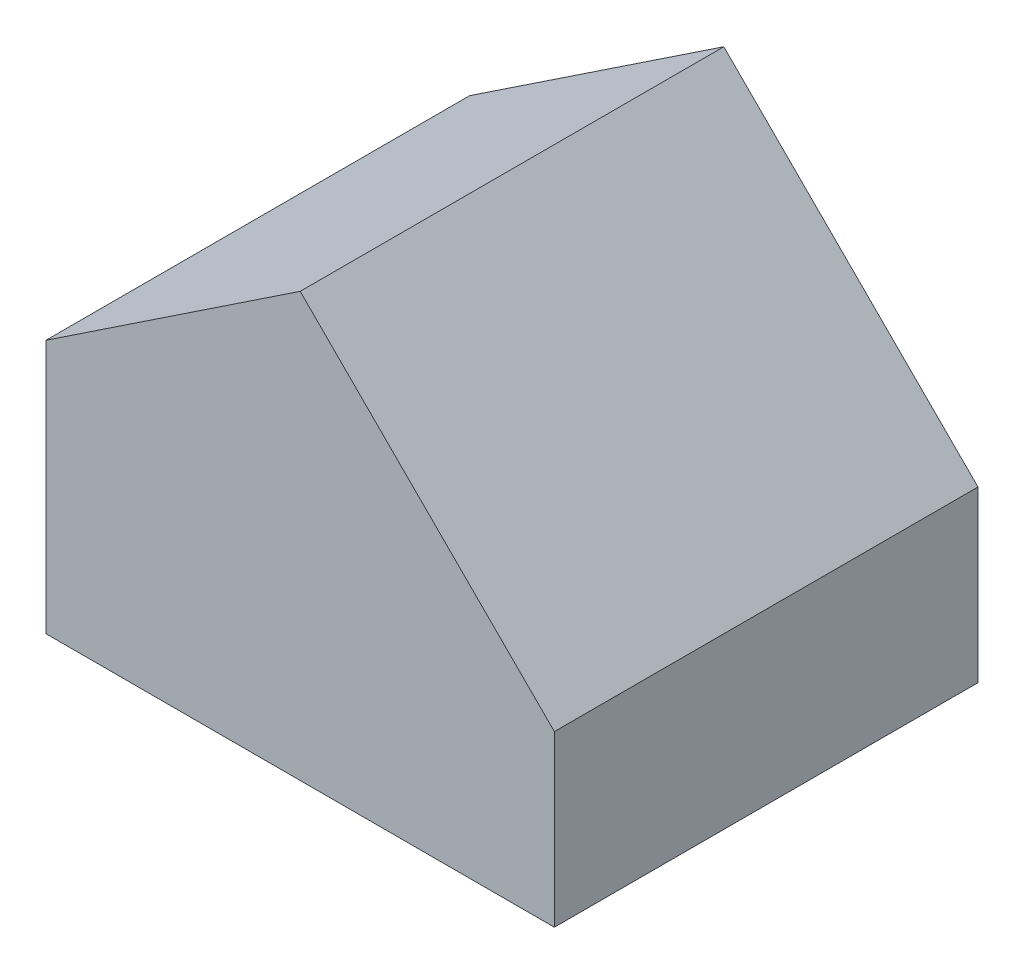
from build123d import *

# Parameters (mm, degrees)
BOSS_EXTRUDE1_DEPTH = 25


with BuildPart() as part:
    # Sketch1 → Boss-Extrude1 (new body)
    with BuildSketch(Plane.XY):
        Polygon((-30, 15), (-15, 25), (0, 10), (0, 0), (-30, 0), align=None)
    extrude(amount=BOSS_EXTRUDE1_DEPTH)


solid = part.part
